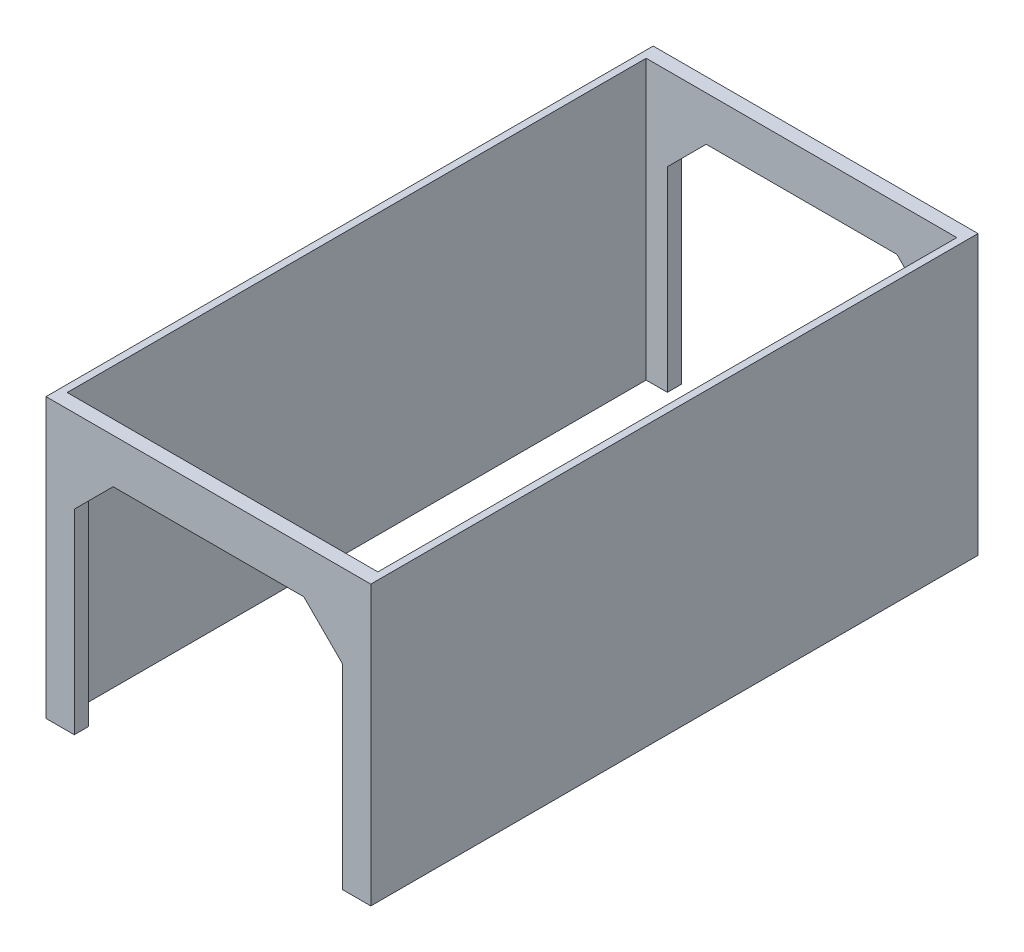
from build123d import *

# Parameters (mm, degrees)
BOSS_EXTRUDE5_DEPTH  = 430
SKETCH6_W            = 220
SKETCH6_H            = 410
CUT_EXTRUDE5_DEPTH   = 430
SKETCH7_W            = 7
SKETCH7_H            = 30
BOSS_EXTRUDE6_DEPTH  = 30
SKETCH8_W            = 7
SKETCH8_H            = 30
BOSS_EXTRUDE7_DEPTH  = 30
BOSS_EXTRUDE8_DEPTH  = 28
CUT_EXTRUDE6_DEPTH   = 430
BOSS_EXTRUDE9_DEPTH  = 38.4
SKETCH12_W           = 430
SKETCH12_H           = 6
CUT_EXTRUDE7_DEPTH   = 500
SKETCH13_W           = 15.031983572
SKETCH13_H           = 10
BOSS_EXTRUDE10_DEPTH = 15
SKETCH14_W           = 14.940905272
SKETCH14_H           = 10
SKETCH14_W_2         = 5
SKETCH14_H_2         = 410
BOSS_EXTRUDE11_DEPTH = 15


with BuildPart() as part:
    # Sketch1 → Boss-Extrude5 (new body)
    with BuildSketch(Plane.XY):
        Polygon((230, 122), (0, 122), (0, 0), (50, 0), (50, 30), (28.531983572, 30), (28.531983572, 38.499978431), (20.031983572, 38.499978431), (20.031983572, 62.999978431), (47.532005141, 90.5), (182.467994859, 90.5), (182.559073159, 90.5), (210.059094728, 62.999978431), (210.059094728, 38.499978431), (209.968016428, 38.499978431), (201.559094728, 38.499978431), (201.559094728, 30), (201.468016428, 30), (180, 30), (180, 0), (230, 0), align=None)
    extrude(amount=BOSS_EXTRUDE5_DEPTH)

    # Sketch6 → Cut-Extrude5 (cut)
    with BuildSketch(Plane(origin=(0, 122, 0), x_dir=(1, 0, 0), z_dir=(0, 1, 0))):
        with Locations((115, -215)):
            Rectangle(SKETCH6_W, SKETCH6_H)
    extrude(amount=-CUT_EXTRUDE5_DEPTH, mode=Mode.SUBTRACT)

    # Sketch7 → Boss-Extrude6 (add)
    with BuildSketch(Plane.XY.offset(10)):
        with Locations((46.5, 15)):
            Rectangle(SKETCH7_W, SKETCH7_H)
        with Locations((183.5, 15)):
            Rectangle(SKETCH7_W, SKETCH7_H)
    extrude(amount=BOSS_EXTRUDE6_DEPTH)

    # Sketch8 → Boss-Extrude7 (add)
    with BuildSketch(Plane(origin=(0, 0, 420), x_dir=(-1, 0, 0), z_dir=(0, 0, -1))):
        with Locations((-183.5, 15)):
            Rectangle(SKETCH8_W, SKETCH8_H)
        with Locations((-46.5, 15)):
            Rectangle(SKETCH8_W, SKETCH8_H)
    extrude(amount=BOSS_EXTRUDE7_DEPTH)

    # Sketch9 → Boss-Extrude8 (add)
    with BuildSketch(Plane.XZ):
        Polygon((50, 430), (0, 430), (0, 0), (50, 0), (50, 40), (43, 40), (43, 10), (5, 10), (5, 420), (43, 420), (43, 390), (50, 390), align=None)
        Polygon((187, 420), (225, 420), (225, 10), (187, 10), (187, 40), (180, 40), (180, 0), (230, 0), (230, 430), (180, 430), (180, 390), (187, 390), align=None)
    extrude(amount=BOSS_EXTRUDE8_DEPTH)

    # Sketch10 → Cut-Extrude6 (cut)
    with BuildSketch(Plane(origin=(0, 0, 0), x_dir=(-1, 0, 0), z_dir=(0, 0, -1))):
        Polygon((-201.559094728, 38.499978431), (-210.059094728, 38.499978431), (-210.059094728, -28), (-180, -28), (-180, 30), (-201.559094728, 30), align=None)
        Polygon((-28.531983572, 30), (-50, 30), (-50, -28), (-20.031983572, -28), (-20.031983572, 30), (-20.031983572, 38.499978431), (-28.531983572, 38.499978431), align=None)
    extrude(amount=-CUT_EXTRUDE6_DEPTH, mode=Mode.SUBTRACT)

    # Sketch11 → Boss-Extrude9 (add)
    with BuildSketch(Plane.XZ.offset(28)):
        Polygon((230, 0), (225, 0), (210.059094728, 0), (210.059094728, 10), (225, 10), (225, 420), (210.059094728, 420), (210.059094728, 430), (230, 430), (230, 420), align=None)
        Polygon((5, 10), (5, 420), (20.031983572, 420), (20.031983572, 430), (5, 430), (0, 430), (0, 10), (0, 0), (20.031983572, 0), (20.031983572, 10), align=None)
    extrude(amount=BOSS_EXTRUDE9_DEPTH)

    # Sketch12 → Cut-Extrude7 (cut)
    with BuildSketch(Plane.ZY):
        with Locations((215, -63.4)):
            Rectangle(SKETCH12_W, SKETCH12_H)
    extrude(amount=-CUT_EXTRUDE7_DEPTH, mode=Mode.SUBTRACT)

    # Sketch13 → Boss-Extrude10 (add)
    with BuildSketch(Plane.XZ.offset(60.4)):
        with Locations((12.515991786, 425)):
            Rectangle(SKETCH13_W, SKETCH13_H)
        Polygon((5, 430), (0, 430), (0, 10), (5, 10), (5, 420), align=None)
        Polygon((5, 10), (0, 10), (0, 0), (20.031983572, 0), (20.031983572, 10), align=None)
    extrude(amount=BOSS_EXTRUDE10_DEPTH)

    # Sketch14 → Boss-Extrude11 (add)
    with BuildSketch(Plane.XZ.offset(60.4)):
        with Locations((217.529547364, 425)):
            Rectangle(SKETCH14_W, SKETCH14_H)
        with Locations((227.5, 425)):
            Rectangle(SKETCH14_W_2, SKETCH14_H)
        with Locations((227.5, 215)):
            Rectangle(SKETCH14_W_2, SKETCH14_H_2)
        Polygon((230, 0), (230, 10), (225, 10), (210.059094728, 10), (210.059094728, 0), align=None)
    extrude(amount=BOSS_EXTRUDE11_DEPTH)


solid = part.part
